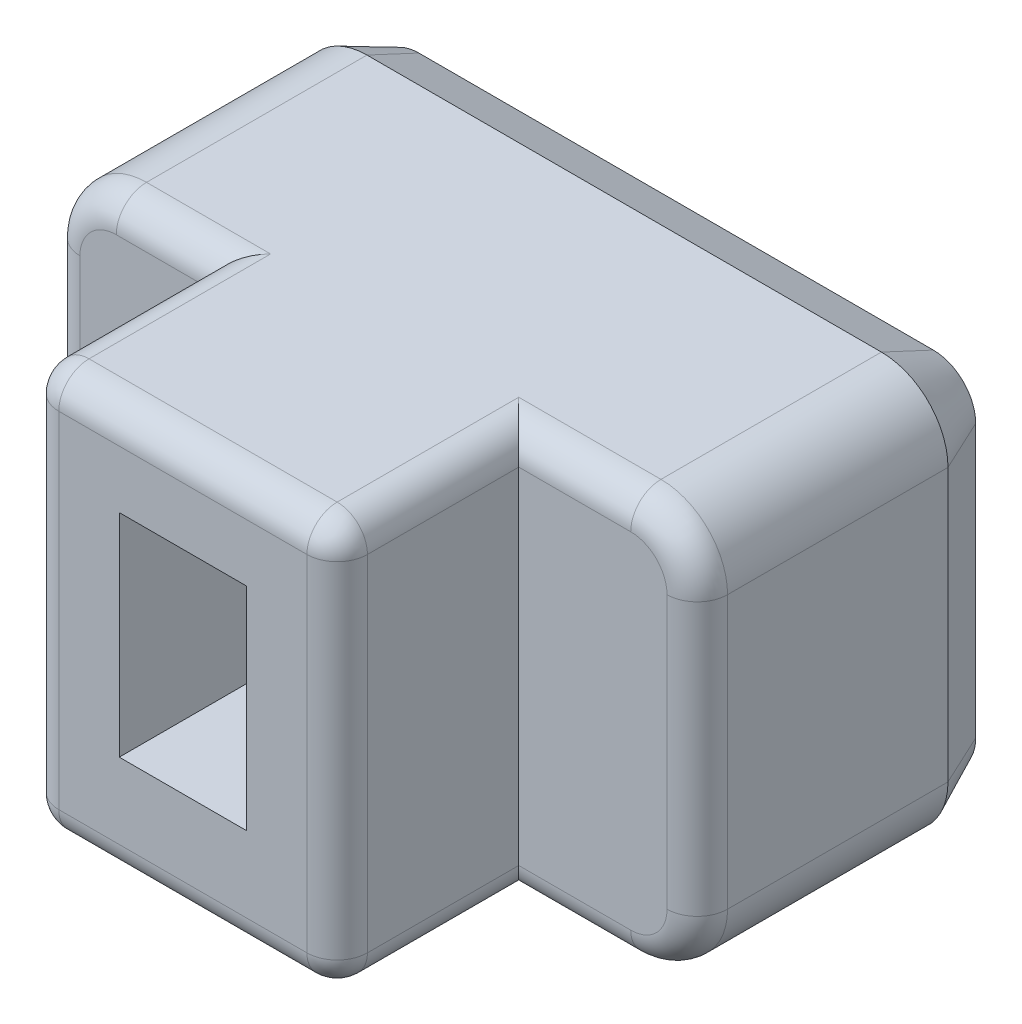
from build123d import *

# Parameters (mm, degrees)
BOSS_EXTRU_1_DEPTH      = 8
ESQUISSE3_W             = 2.1
ESQUISSE3_H             = 3.5
ENL_V_MAT_EXTRU_1_DEPTH = 3
ESQUISSE4_OUTSIDE_W     = 15.69
ESQUISSE4_OUTSIDE_H     = 11.69
ESQUISSE4_OUTSIDE_W_2   = 5.1
ESQUISSE4_OUTSIDE_H_2   = 6.7
ENL_V_MAT_EXTRU_2_DEPTH = 3
CONG_1_R                = 0.5
CHANFREIN1_SIZE         = 0.4
CHANFREIN1_SIZE2        = 0.857802768
ENL_V_MAT_EXTRU_3_DEPTH = 0.2
BOSS_EXTRU_2_DEPTH      = 0.2
BOSS_EXTRU_2_2_DEPTH    = 0.2
BOSS_EXTRU_2_3_DEPTH    = 0.2


with BuildPart() as part:
    # Esquisse2 → Boss.-Extru.1 (new body)
    with BuildSketch(Plane.XY):
        with BuildLine():
            Line((1.1, 0), (9.6, 0))
            ThreePointArc((9.6, 0), (10.377817459, 0.322182541), (10.7, 1.1))
            Line((10.7, 1.1), (10.7, 5.6))
            ThreePointArc((10.7, 5.6), (10.377817459, 6.377817459), (9.6, 6.7))
            Line((9.6, 6.7), (1.1, 6.7))
            ThreePointArc((1.1, 6.7), (0.322182541, 6.377817459), (0, 5.6))
            Line((0, 5.6), (0, 1.1))
            ThreePointArc((0, 1.1), (0.322182541, 0.322182541), (1.1, 0))
        make_face()
    extrude(amount=BOSS_EXTRU_1_DEPTH)

    # Esquisse3 → Enlèv. mat.-Extru.1 (cut)
    with BuildSketch(Plane.XY.offset(8)):
        with Locations((5.2, 3.5)):
            Rectangle(ESQUISSE3_W, ESQUISSE3_H)
    extrude(amount=-ENL_V_MAT_EXTRU_1_DEPTH, mode=Mode.SUBTRACT)

    # Esquisse4 outside → Enlèv. mat.-Extru.2 (cut)
    with BuildSketch(Plane.XY.offset(8)):
        with Locations((5.35, 3.35)):
            Rectangle(ESQUISSE4_OUTSIDE_W, ESQUISSE4_OUTSIDE_H)
        with Locations((5.2, 3.35)):
            Rectangle(ESQUISSE4_OUTSIDE_W_2, ESQUISSE4_OUTSIDE_H_2, mode=Mode.SUBTRACT)
    extrude(amount=-ENL_V_MAT_EXTRU_2_DEPTH, mode=Mode.SUBTRACT)

    # Congé1
    cong_1_edges = [part.edges().sort_by_distance(p)[0] for p in [
        (8.675, 0, 5),
        (10.377817459, 0.322182541, 5),
        (10.7, 3.35, 5),
        (10.377817459, 6.377817459, 5),
        (1.875, 6.7, 5),
        (0.322182541, 6.377817459, 5),
        (1.875, 0, 5),
        (0.322182541, 0.322182541, 5),
        (7.75, 6.7, 6.5),
        (2.65, 6.7, 6.5),
        (7.75, 0, 6.5),
        (2.65, 0, 6.5),
        (2.65, 3.35, 8),
        (5.2, 6.7, 8),
        (7.75, 3.35, 8),
        (5.2, 0, 8),
        (8.675, 6.7, 5),
        (0, 3.35, 5),
    ]]
    fillet(cong_1_edges, radius=CONG_1_R)

    # Chanfrein1
    chanfrein1_edges = [part.edges().sort_by_distance(p)[0] for p in [
        (5.35, 0, 0),
        (10.377817459, 0.322182541, 0),
        (0.322182541, 0.322182541, 0),
        (10.7, 3.35, 0),
        (0, 3.35, 0),
        (10.377817459, 6.377817459, 0),
        (0.322182541, 6.377817459, 0),
        (5.35, 6.7, 0),
    ]]
    chanfrein1_side = [part.faces().sort_by_distance(p)[0] for p in [
        (5.35, 3.35, 0),
    ]]
    chamfer(chanfrein1_edges, length=CHANFREIN1_SIZE, length2=CHANFREIN1_SIZE2, reference=chanfrein1_side[0])

    # Esquisse5 → Enlèv. mat.-Extru.3 (cut)
    # profile 1 of 3: a face of its own
    with BuildSketch(Plane.XY):
        Polygon((2.004839382, 5.092998901), (1.561177411, 5.092998901), (1.561177411, 1.592998901), (3.655477587, 1.592998901), (3.655477587, 1.987365098), (2.004839382, 1.987365098), (2.004839382, 3.121167915), (3.468307692, 3.121167915), (3.468307692, 3.515534112), (2.004839382, 3.515534112), align=None)
    # profile 2 of 3: a face of its own
    with BuildSketch(Plane.XY):
        with BuildLine():
            Line((4.666811213, 5.092998901), (4.223149242, 5.092998901))
            Line((4.223149242, 5.092998901), (4.223149242, 1.592998901))
            Line((4.223149242, 1.592998901), (5.200592023, 1.592998901))
            add(Edge.make_bspline(
                [(5.200592023, 1.592998901), (5.270736782, 1.594346136), (5.405913067, 1.596942398), (5.600586131, 1.616223888), (5.78035089, 1.64768101), (5.892061515, 1.682965939), (5.946190615, 1.700063162)],
                knots=[0, 0, 0, 0, 1.112355922, 2.143626162, 3.100498776, 4, 4, 4, 4], degree=3))
            add(Edge.make_bspline(
                [(5.946190615, 1.700063162), (5.972005235, 1.709737175), (6.02246174, 1.72864572), (6.094343702, 1.762186281), (6.161771658, 1.798224428), (6.224397151, 1.838356581), (6.282115877, 1.882405863), (6.335463076, 1.929209213), (6.38363927, 1.979741626), (6.426961304, 2.033849581), (6.465183453, 2.091413228), (6.498947525, 2.151985234), (6.526281441, 2.216225707), (6.549730109, 2.283268423), (6.567236743, 2.353982425), (6.580319683, 2.427548027), (6.588269943, 2.504538842), (6.588982302, 2.55681491), (6.589346425, 2.583535873)],
                knots=[0, 0, 0, 0, 1.124442718, 2.197803028, 3.233701671, 4.242060162, 5.228912013, 6.193721093, 7.134748139, 8.073848942, 9.018135772, 9.951198787, 10.898965802, 11.863035237, 12.846322021, 13.867657241, 14.910050942, 16, 16, 16, 16], degree=3))
            add(Edge.make_bspline(
                [(6.589346425, 2.583535873), (6.587954678, 2.626738948), (6.58524781, 2.710766449), (6.565963344, 2.83297027), (6.532830246, 2.946864419), (6.486236781, 3.052829138), (6.426498715, 3.150178586), (6.355077044, 3.239433411), (6.271894039, 3.320342264), (6.176171462, 3.391909943), (6.069577428, 3.455872249), (5.95163871, 3.511487602), (5.822820671, 3.55798912), (5.683510951, 3.59660608), (5.533820853, 3.625933158), (5.374501453, 3.648780099), (5.205387313, 3.660419336), (5.08969109, 3.662403864), (5.030367551, 3.663421436)],
                knots=[0, 0, 0, 0, 0.968718608, 1.884102052, 2.765986235, 3.621885972, 4.472131014, 5.320111439, 6.179278092, 7.067156968, 7.994397575, 8.962825233, 9.98653845, 11.062207755, 12.201593465, 13.405123921, 14.669470551, 16, 16, 16, 16], degree=3))
            add(Edge.make_bspline(
                [(5.030367551, 3.663421436), (4.97077673, 3.662735044), (4.849434286, 3.661337369), (4.728403985, 3.652509197), (4.666811213, 3.648016507)],
                knots=[0, 0, 0, 0, 0.982192539, 2, 2, 2, 2], degree=3))
            Line((4.666811213, 3.648016507), (4.666811213, 5.092998901))
        make_face()
        with BuildLine():
            add(Edge.make_bspline(
                [(4.666811213, 3.248258584), (4.695286728, 3.251597289), (4.753672778, 3.258442953), (4.841864703, 3.263845968), (4.929427978, 3.267959104), (4.986972299, 3.26869654), (5.014962622, 3.269055239)],
                knots=[0, 0, 0, 0, 0.985741249, 2.021158771, 3.037465329, 4, 4, 4, 4], degree=3))
            add(Edge.make_bspline(
                [(5.014962622, 3.269055239), (5.061959212, 3.26843136), (5.152438478, 3.26723025), (5.282826542, 3.259028095), (5.402401811, 3.24447471), (5.511276696, 3.224697161), (5.610121344, 3.199603873), (5.698797713, 3.167768316), (5.778837527, 3.131917452), (5.849216231, 3.090424254), (5.910326557, 3.043663677), (5.962334207, 2.992008966), (6.005133975, 2.935067751), (6.039504796, 2.873696183), (6.064664879, 2.807323141), (6.083385781, 2.736909697), (6.094057215, 2.661911583), (6.095600937, 2.610526998), (6.096388678, 2.584306119)],
                knots=[0, 0, 0, 0, 1.553945874, 2.991703872, 4.317422507, 5.534619706, 6.64858697, 7.685068661, 8.646218749, 9.5445405, 10.379967423, 11.184365228, 11.960305534, 12.727981732, 13.502062159, 14.301020985, 15.133033313, 16, 16, 16, 16], degree=3))
            add(Edge.make_bspline(
                [(6.096388678, 2.584306119), (6.095246099, 2.552383196), (6.093052161, 2.491086033), (6.07520693, 2.403357828), (6.045138167, 2.324650202), (6.002915575, 2.254631345), (5.948703326, 2.194467149), (5.885464528, 2.141155705), (5.811753723, 2.096362639), (5.757557097, 2.07370406), (5.729751354, 2.062079007)],
                knots=[0, 0, 0, 0, 1.117625135, 2.146020576, 3.119828649, 4.056154575, 4.992826041, 5.944066922, 6.945197298, 8, 8, 8, 8], degree=3))
            add(Edge.make_bspline(
                [(5.729751354, 2.062079007), (5.690729242, 2.04927612), (5.608821911, 2.02240289), (5.498931729, 2.004691976), (5.402732058, 1.996214758), (5.322873684, 1.99065256), (5.237074864, 1.987614178), (5.178000518, 1.987450011), (5.147445016, 1.987365098)],
                knots=[0, 0, 0, 0, 1.251296077, 2.626467778, 3.38164455, 4.198024017, 5.067949374, 6, 6, 6, 6], degree=3))
            Line((5.147445016, 1.987365098), (4.666811213, 1.987365098))
            Line((4.666811213, 1.987365098), (4.666811213, 3.248258584))
        make_face(mode=Mode.SUBTRACT)
    # profile 3 of 3: a face of its own
    with BuildSketch(Plane.XY):
        Polygon((7.723149242, 1.592998901), (7.723149242, 4.698632704), (9.420772481, 4.698632704), (9.420772481, 5.092998901), (7.27948727, 5.092998901), (7.27948727, 1.592998901), align=None)
    extrude(amount=ENL_V_MAT_EXTRU_3_DEPTH, mode=Mode.SUBTRACT)


with BuildPart() as body_2:
    # Esquisse5_4 → Boss.-Extru.2 (new body)
    with BuildSketch(Plane.XY):
        Polygon((2.004839382, 5.092998901), (1.561177411, 5.092998901), (1.561177411, 1.592998901), (3.655477587, 1.592998901), (3.655477587, 1.987365098), (2.004839382, 1.987365098), (2.004839382, 3.121167915), (3.468307692, 3.121167915), (3.468307692, 3.515534112), (2.004839382, 3.515534112), align=None)
    extrude(amount=-BOSS_EXTRU_2_DEPTH)


with BuildPart() as body_3:
    # Esquisse5_4 → Boss.-Extru.2 2 (new body)
    with BuildSketch(Plane.XY):
        with BuildLine():
            Line((4.666811213, 5.092998901), (4.223149242, 5.092998901))
            Line((4.223149242, 5.092998901), (4.223149242, 1.592998901))
            Line((4.223149242, 1.592998901), (5.200592023, 1.592998901))
            add(Edge.make_bspline(
                [(5.200592023, 1.592998901), (5.270736782, 1.594346136), (5.405913067, 1.596942398), (5.600586131, 1.616223888), (5.78035089, 1.64768101), (5.892061515, 1.682965939), (5.946190615, 1.700063162)],
                knots=[0, 0, 0, 0, 1.112355922, 2.143626162, 3.100498776, 4, 4, 4, 4], degree=3))
            add(Edge.make_bspline(
                [(5.946190615, 1.700063162), (5.972005235, 1.709737175), (6.02246174, 1.72864572), (6.094343702, 1.762186281), (6.161771658, 1.798224428), (6.224397151, 1.838356581), (6.282115877, 1.882405863), (6.335463076, 1.929209213), (6.38363927, 1.979741626), (6.426961304, 2.033849581), (6.465183453, 2.091413228), (6.498947525, 2.151985234), (6.526281441, 2.216225707), (6.549730109, 2.283268423), (6.567236743, 2.353982425), (6.580319683, 2.427548027), (6.588269943, 2.504538842), (6.588982302, 2.55681491), (6.589346425, 2.583535873)],
                knots=[0, 0, 0, 0, 1.124442718, 2.197803028, 3.233701671, 4.242060162, 5.228912013, 6.193721093, 7.134748139, 8.073848942, 9.018135772, 9.951198787, 10.898965802, 11.863035237, 12.846322021, 13.867657241, 14.910050942, 16, 16, 16, 16], degree=3))
            add(Edge.make_bspline(
                [(6.589346425, 2.583535873), (6.587954678, 2.626738948), (6.58524781, 2.710766449), (6.565963344, 2.83297027), (6.532830246, 2.946864419), (6.486236781, 3.052829138), (6.426498715, 3.150178586), (6.355077044, 3.239433411), (6.271894039, 3.320342264), (6.176171462, 3.391909943), (6.069577428, 3.455872249), (5.95163871, 3.511487602), (5.822820671, 3.55798912), (5.683510951, 3.59660608), (5.533820853, 3.625933158), (5.374501453, 3.648780099), (5.205387313, 3.660419336), (5.08969109, 3.662403864), (5.030367551, 3.663421436)],
                knots=[0, 0, 0, 0, 0.968718608, 1.884102052, 2.765986235, 3.621885972, 4.472131014, 5.320111439, 6.179278092, 7.067156968, 7.994397575, 8.962825233, 9.98653845, 11.062207755, 12.201593465, 13.405123921, 14.669470551, 16, 16, 16, 16], degree=3))
            add(Edge.make_bspline(
                [(5.030367551, 3.663421436), (4.97077673, 3.662735044), (4.849434286, 3.661337369), (4.728403985, 3.652509197), (4.666811213, 3.648016507)],
                knots=[0, 0, 0, 0, 0.982192539, 2, 2, 2, 2], degree=3))
            Line((4.666811213, 3.648016507), (4.666811213, 5.092998901))
        make_face()
        with BuildLine():
            add(Edge.make_bspline(
                [(4.666811213, 3.248258584), (4.695286728, 3.251597289), (4.753672778, 3.258442953), (4.841864703, 3.263845968), (4.929427978, 3.267959104), (4.986972299, 3.26869654), (5.014962622, 3.269055239)],
                knots=[0, 0, 0, 0, 0.985741249, 2.021158771, 3.037465329, 4, 4, 4, 4], degree=3))
            add(Edge.make_bspline(
                [(5.014962622, 3.269055239), (5.061959212, 3.26843136), (5.152438478, 3.26723025), (5.282826542, 3.259028095), (5.402401811, 3.24447471), (5.511276696, 3.224697161), (5.610121344, 3.199603873), (5.698797713, 3.167768316), (5.778837527, 3.131917452), (5.849216231, 3.090424254), (5.910326557, 3.043663677), (5.962334207, 2.992008966), (6.005133975, 2.935067751), (6.039504796, 2.873696183), (6.064664879, 2.807323141), (6.083385781, 2.736909697), (6.094057215, 2.661911583), (6.095600937, 2.610526998), (6.096388678, 2.584306119)],
                knots=[0, 0, 0, 0, 1.553945874, 2.991703872, 4.317422507, 5.534619706, 6.64858697, 7.685068661, 8.646218749, 9.5445405, 10.379967423, 11.184365228, 11.960305534, 12.727981732, 13.502062159, 14.301020985, 15.133033313, 16, 16, 16, 16], degree=3))
            add(Edge.make_bspline(
                [(6.096388678, 2.584306119), (6.095246099, 2.552383196), (6.093052161, 2.491086033), (6.07520693, 2.403357828), (6.045138167, 2.324650202), (6.002915575, 2.254631345), (5.948703326, 2.194467149), (5.885464528, 2.141155705), (5.811753723, 2.096362639), (5.757557097, 2.07370406), (5.729751354, 2.062079007)],
                knots=[0, 0, 0, 0, 1.117625135, 2.146020576, 3.119828649, 4.056154575, 4.992826041, 5.944066922, 6.945197298, 8, 8, 8, 8], degree=3))
            add(Edge.make_bspline(
                [(5.729751354, 2.062079007), (5.690729242, 2.04927612), (5.608821911, 2.02240289), (5.498931729, 2.004691976), (5.402732058, 1.996214758), (5.322873684, 1.99065256), (5.237074864, 1.987614178), (5.178000518, 1.987450011), (5.147445016, 1.987365098)],
                knots=[0, 0, 0, 0, 1.251296077, 2.626467778, 3.38164455, 4.198024017, 5.067949374, 6, 6, 6, 6], degree=3))
            Line((5.147445016, 1.987365098), (4.666811213, 1.987365098))
            Line((4.666811213, 1.987365098), (4.666811213, 3.248258584))
        make_face(mode=Mode.SUBTRACT)
    extrude(amount=-BOSS_EXTRU_2_2_DEPTH)


with BuildPart() as body_4:
    # Esquisse5_4 → Boss.-Extru.2 3 (new body)
    with BuildSketch(Plane.XY):
        Polygon((7.723149242, 1.592998901), (7.723149242, 4.698632704), (9.420772481, 4.698632704), (9.420772481, 5.092998901), (7.27948727, 5.092998901), (7.27948727, 1.592998901), align=None)
    extrude(amount=-BOSS_EXTRU_2_3_DEPTH)


solid = Compound([part.part, body_2.part, body_3.part, body_4.part])
